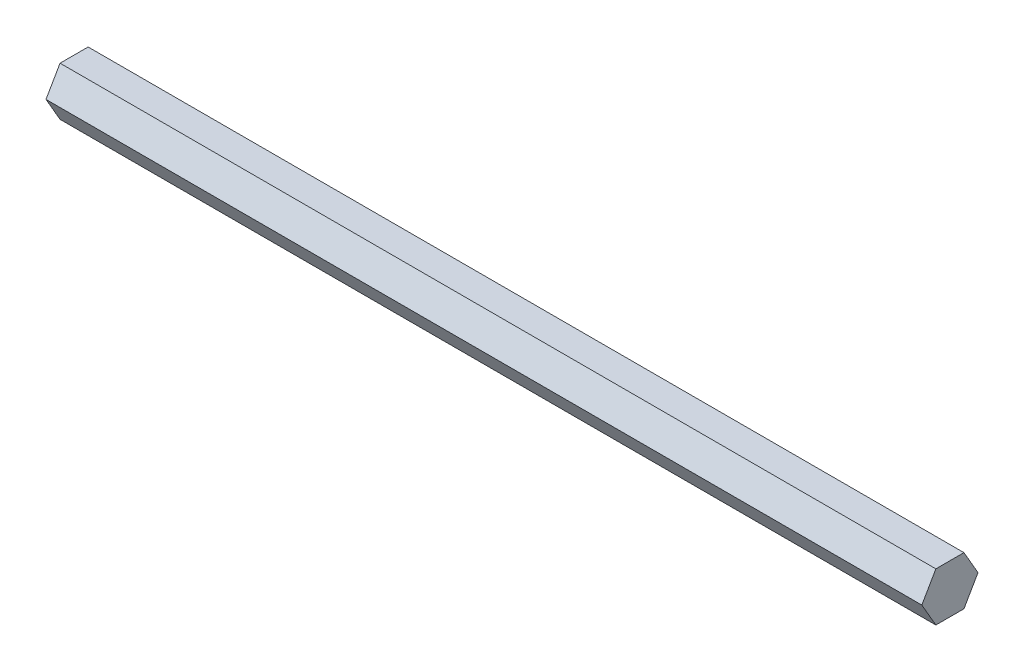
from build123d import *

# Parameters (mm, degrees)
BOSS_EXTRUDE1_DEPTH = 228.6


with BuildPart() as part:
    # Sketch1 → Boss-Extrude1 (new body)
    with BuildSketch(Plane(origin=(0, 0, 0), x_dir=(0, -1, 0), z_dir=(-1, 0, 0))):
        Polygon((-6.35, 3.666174209), (-6.35, -3.666174209), (0, -7.332348419), (6.35, -3.666174209), (6.35, 3.666174209), (0, 7.332348419), align=None)
    extrude(amount=-BOSS_EXTRUDE1_DEPTH)


solid = part.part
